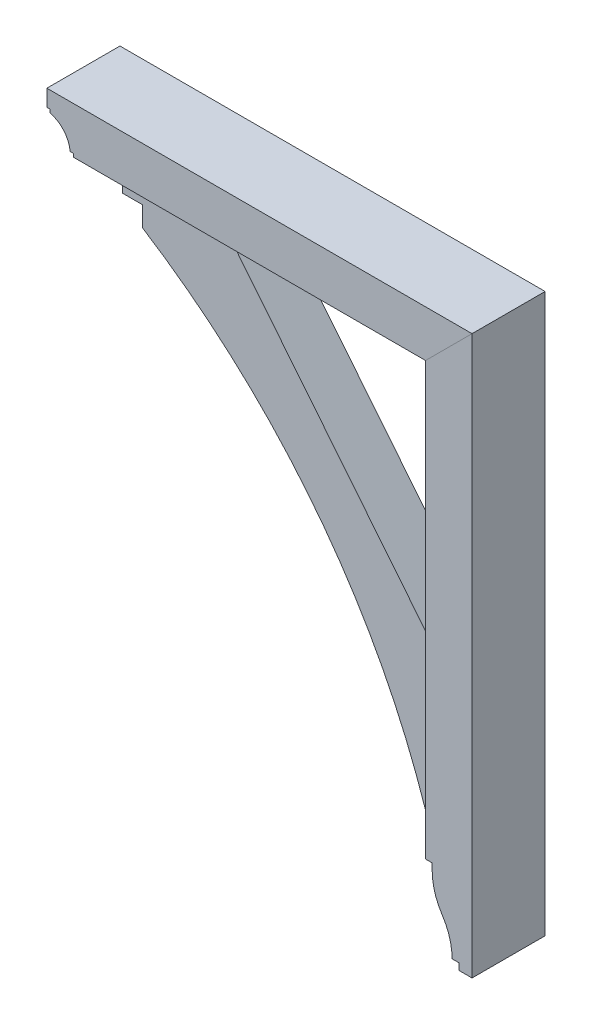
from build123d import *

# Parameters (mm, degrees)
BOSS_EXTRUDE1_DEPTH = 69.85
BOSS_EXTRUDE2_DEPTH = 44.45
BOSS_EXTRUDE3_DEPTH = 69.85


with BuildPart() as part:
    # Sketch1 → Boss-Extrude1 (new body, symmetric)
    with BuildSketch(Plane.XY):
        with BuildLine():
            Line((-483.368776984, 692.785), (-483.368776984, 699.135))
            Line((-483.368776984, 699.135), (-489.718776984, 699.135))
            Line((-489.718776984, 699.135), (-489.718776984, 730.885))
            Line((-489.718776984, 730.885), (323.081223016, 730.885))
            Line((323.081223016, 730.885), (234.181223016, 641.985))
            Line((234.181223016, 641.985), (-438.918776984, 641.985))
            Line((-438.918776984, 641.985), (-438.918776984, 648.335))
            Line((-438.918776984, 648.335), (-445.268776984, 648.335))
            ThreePointArc((-445.268776984, 648.335), (-457.260423906, 676.610016924), (-483.368776984, 692.785))
        make_face()
    extrude(amount=BOSS_EXTRUDE1_DEPTH, both=True)


with BuildPart() as body_2:
    # Sketch1_3 → Boss-Extrude2 (new body, symmetric)
    with BuildSketch(Plane.XY):
        with BuildLine():
            Line((234.181223016, 137.16), (-172.218776984, 641.985))
            Line((-172.218776984, 641.985), (-370.656276984, 641.985))
            Line((-370.656276984, 641.985), (-370.656276984, 603.885))
            Line((-370.656276984, 603.885), (-332.556276984, 603.885))
            Line((-332.556276984, 603.885), (-332.556276984, 565.785))
            ThreePointArc((-332.556276984, 565.785), (-1.802905594, 265.801503762), (208.781223016, -127.9525))
            Line((208.781223016, -127.9525), (234.181223016, -127.9525))
            Line((234.181223016, -127.9525), (234.181223016, 137.16))
        make_face()
    extrude(amount=BOSS_EXTRUDE2_DEPTH, both=True)


with BuildPart() as body_3:
    # Sketch1_4 → Boss-Extrude3 (new body, symmetric)
    with BuildSketch(Plane.XY):
        with BuildLine():
            Line((323.081223016, -335.915), (323.081223016, 730.885))
            Line((323.081223016, 730.885), (234.181223016, 641.985))
            Line((234.181223016, 641.985), (234.181223016, -183.515))
            Line((234.181223016, -183.515), (246.881223016, -183.515))
            Line((246.881223016, -183.515), (246.881223016, -196.215))
            ThreePointArc((246.881223016, -196.215), (251.768629387, -229.515028089), (266.018608337, -260.006284404))
            ThreePointArc((266.018608337, -260.006284404), (280.138450492, -290.219081757), (284.981223016, -323.215))
            Line((284.981223016, -323.215), (297.681223016, -323.215))
            Line((297.681223016, -323.215), (297.681223016, -335.915))
            Line((297.681223016, -335.915), (323.081223016, -335.915))
        make_face()
    extrude(amount=BOSS_EXTRUDE3_DEPTH, both=True)


solid = Compound([part.part, body_2.part, body_3.part])
